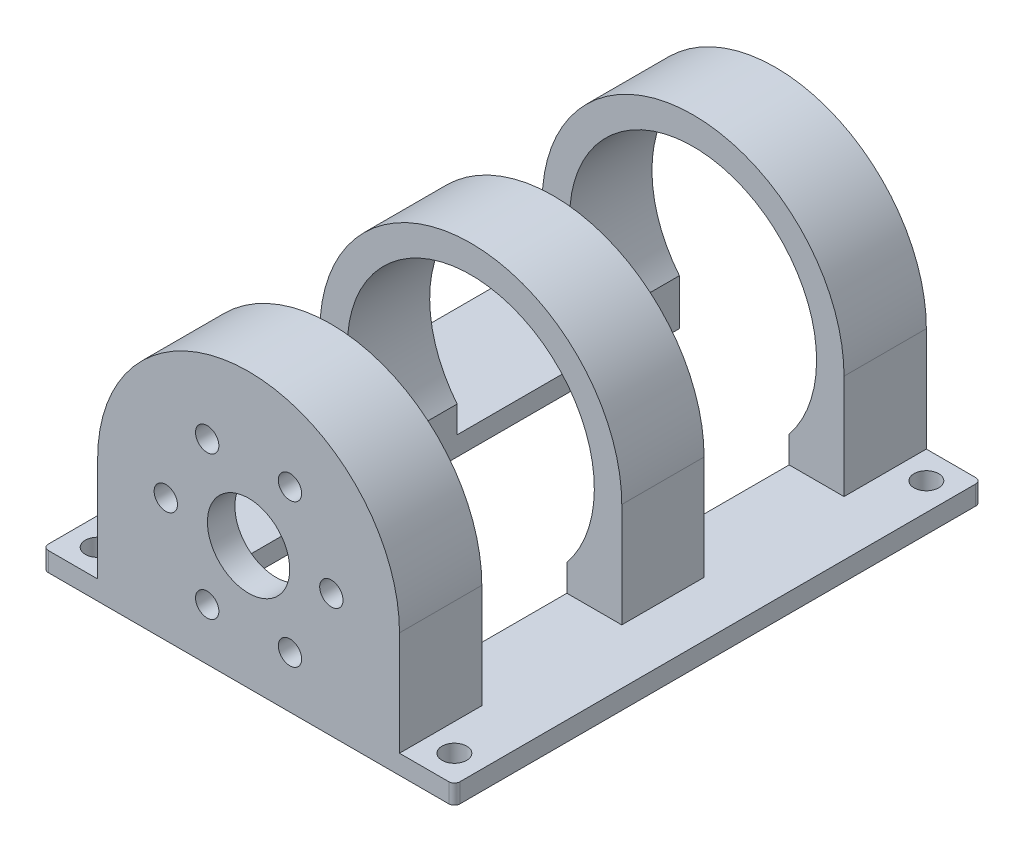
from build123d import *

# Parameters (mm, degrees)
BOSS_EXTRUDE2_DEPTH = 96
SKETCH4_W           = 10
SKETCH4_H           = 96
SKETCH4_R           = 2.25
BOSS_EXTRUDE3_DEPTH = 3.5
BOSS_EXTRUDE4_START = -5
BOSS_EXTRUDE4_DEPTH = 5
SKETCH6_R           = 2.125
CUT_EXTRUDE1_DEPTH  = 5
SKETCH7_R           = 7.5
CUT_EXTRUDE2_DEPTH  = 97
SKETCH8_W           = 55
SKETCH8_H           = 25.5
CUT_EXTRUDE3_DEPTH  = 47.5
FILLET1_R           = 1


with BuildPart() as part:
    # Sketch1 → Boss-Extrude2 (new body)
    with BuildSketch(Plane.XY):
        with BuildLine():
            Line((-27.5, -22.5), (-27.5, 0))
            ThreePointArc((-27.5, 0), (0, 27.5), (27.5, 0))
            Line((27.5, 0), (27.5, -22.5))
            Line((27.5, -22.5), (17.5, -22.5))
            Line((17.5, -22.5), (17.5, -14.142135624))
            ThreePointArc((17.5, -14.142135624), (0, 22.5), (-17.5, -14.142135624))
            Line((-17.5, -14.142135624), (-17.5, -22.5))
            Line((-17.5, -22.5), (-27.5, -22.5))
        make_face()
    extrude(amount=BOSS_EXTRUDE2_DEPTH)

    # Sketch4 → Boss-Extrude3 (add)
    with BuildSketch(Plane.XZ.offset(22.5)):
        with Locations((-32.5, 48)):
            Rectangle(SKETCH4_W, SKETCH4_H)
        with Locations((-32.5, 91)):
            Circle(SKETCH4_R, mode=Mode.SUBTRACT)
        with Locations((-32.5, 5)):
            Circle(SKETCH4_R, mode=Mode.SUBTRACT)
        with Locations((32.5, 48)):
            Rectangle(SKETCH4_W, SKETCH4_H)
        with Locations((32.5, 5)):
            Circle(SKETCH4_R, mode=Mode.SUBTRACT)
        with Locations((32.5, 91)):
            Circle(SKETCH4_R, mode=Mode.SUBTRACT)
    extrude(amount=-BOSS_EXTRUDE3_DEPTH)

    # Sketch5 → Boss-Extrude4 (add)
    with BuildSketch(Plane.XY.offset(96).offset(BOSS_EXTRUDE4_START)):
        with BuildLine():
            Line((-27.5, -19), (-27.5, 0))
            ThreePointArc((-27.5, 0), (0, 27.5), (27.5, 0))
            Line((27.5, 0), (27.5, -19))
            Line((27.5, -19), (27.5, -22.5))
            Line((27.5, -22.5), (-27.5, -22.5))
            Line((-27.5, -22.5), (-27.5, -19))
        make_face()
    extrude(amount=BOSS_EXTRUDE4_DEPTH)

    # Sketch6 → Cut-Extrude1 (cut)
    with BuildSketch(Plane.XY.offset(96)):
        with Locations((-7.541666667, 13.06254984)):
            Circle(SKETCH6_R)
        with Locations((7.541666667, 13.06254984)):
            Circle(SKETCH6_R)
        with Locations((15.083333333, 0)):
            Circle(SKETCH6_R)
        with Locations((7.541666667, -13.06254984)):
            Circle(SKETCH6_R)
        with Locations((-7.541666667, -13.06254984)):
            Circle(SKETCH6_R)
        with Locations((-15.083333333, 0)):
            Circle(SKETCH6_R)
    extrude(amount=-CUT_EXTRUDE1_DEPTH, mode=Mode.SUBTRACT)

    # Sketch7 → Cut-Extrude2 (cut, through all)
    with BuildSketch(Plane.XY.offset(96)):
        Circle(SKETCH7_R)
    extrude(amount=-CUT_EXTRUDE2_DEPTH, mode=Mode.SUBTRACT)

    # Sketch8 → Cut-Extrude3 (cut, through all)
    with BuildSketch(Plane(origin=(0, -19, 0), x_dir=(1, 0, 0), z_dir=(0, 1, 0))):
        with Locations((0, -27.75)):
            Rectangle(SKETCH8_W, SKETCH8_H)
        with Locations((0, -68.25)):
            Rectangle(SKETCH8_W, SKETCH8_H)
    extrude(amount=CUT_EXTRUDE3_DEPTH, mode=Mode.SUBTRACT)

    # Fillet1
    fillet1_edges = [part.edges().sort_by_distance(p)[0] for p in [
        (-37.5, -20.75, 0),
        (-37.5, -20.75, 96),
        (37.5, -20.75, 96),
        (37.5, -20.75, 0),
    ]]
    fillet(fillet1_edges, radius=FILLET1_R)


solid = part.part
